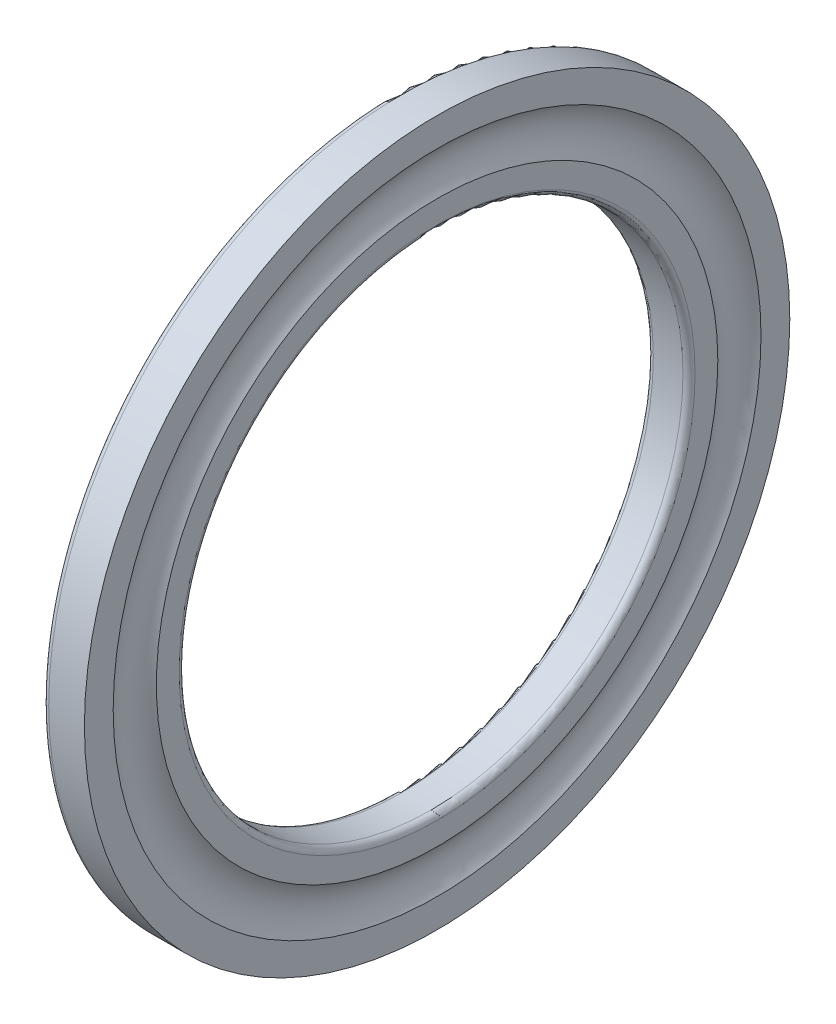
from build123d import *


with BuildPart() as part:
    # Croquis1 → Revolución1 (revolve)
    with BuildSketch(Plane.XY):
        with BuildLine():
            Line((0.6, 25), (3.542, 25))
            ThreePointArc((3.542, 25), (3.966264069, 25.175735931), (4.142, 25.6))
            Line((4.142, 25.6), (4.142, 27.857333437))
            ThreePointArc((4.142, 27.857333437), (3.428, 30), (4.142, 32.142666563))
            Line((4.142, 32.142666563), (4.142, 35))
            Line((4.142, 35), (0.6, 35))
            ThreePointArc((0.6, 35), (0.175735931, 34.824264069), (0, 34.4))
            Line((0, 34.4), (0, 25.6))
            ThreePointArc((0, 25.6), (0.175735931, 25.175735931), (0.6, 25))
        make_face()
    revolve(axis=Axis((3.542, 0, 0), (-1, 0, 0)))


solid = part.part
